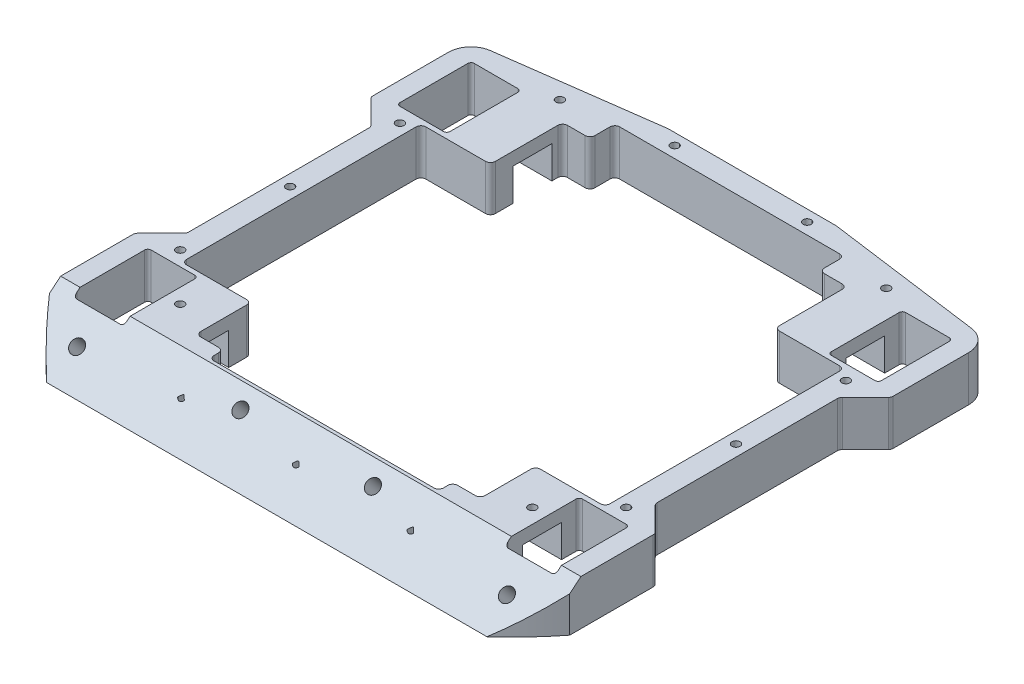
from build123d import *

# Parameters (mm, degrees)
SKETCH1_W                 = 161
SKETCH1_H                 = 154.75
OUTLINE_DEPTH             = 14
SKETCH2_W                 = 15.5
SKETCH2_H                 = 23
THRU_ALL_DEPTH            = 15
SKETCH14_W                = 87.977155452
SKETCH14_H                = 113.473818773
LAZY_EXTRA_DEPTH          = 15
SKETCH3_W                 = 23.5
SKETCH3_H                 = 12
MOTOR_HUTS_DEPTH          = 10
WHEEL_WELL_R              = 1
OUTER_CUTOUTS_DEPTH       = 15
SKETCH13_R                = 119.159432218
SKETCH13_R_2              = 102.197163823
CUT_EXTRUDE1_DEPTH        = 15
FILLET_THE_REST_R         = 1.5
WEDGE_CUT_DEPTH           = 162
TOP_SCREWS_D              = 2.5
TOP_SCREWS_DEPTH          = 6.5
TOP_SCREWS_TIP            = 0.751075774
BOTTOM_SCREWS_D           = 2.5
BOTTOM_SCREWS_DEPTH       = 7.5
BOTTOM_SCREWS_TIP         = 0.751075774
M5X0_8_TAPPED_HOLE1_D     = 4.2
M5X0_8_TAPPED_HOLE1_DEPTH = 7.4
M5X0_8_TAPPED_HOLE1_TIP   = 1.2618073


with BuildPart() as part:
    # Sketch1 → outline (new body)
    with BuildSketch(Plane(origin=(0, 0, 0), x_dir=(1, 0, 0), z_dir=(0, 1, 0))):
        with Locations((0, -3.375)):
            Rectangle(SKETCH1_W, SKETCH1_H)
    extrude(amount=OUTLINE_DEPTH)

    # Sketch2 → thru-all (cut, through all)
    with BuildSketch(Plane(origin=(0, 14, 0), x_dir=(1, 0, 0), z_dir=(0, 1, 0))):
        Polygon((-35.5, 67), (35.5, 67), (35.5, 37), (65.5, 37), (65.5, -37), (35.5, -37), (35.5, -58.5), (-35.5, -58.5), (-35.5, -37), (-65.5, -37), (-65.5, 37), (-35.5, 37), align=None)
        with Locations((-66.75, 50)):
            Rectangle(SKETCH2_W, SKETCH2_H)
        with Locations((66.75, 50)):
            Rectangle(SKETCH2_W, SKETCH2_H)
        with Locations((66.75, -50)):
            Rectangle(SKETCH2_W, SKETCH2_H)
        with Locations((-66.75, -50)):
            Rectangle(SKETCH2_W, SKETCH2_H)
    extrude(amount=-THRU_ALL_DEPTH, mode=Mode.SUBTRACT)

    # Sketch14 → lazy extra (cut, through all)
    with BuildSketch(Plane(origin=(0, 14, 0), x_dir=(1, 0, 0), z_dir=(0, 1, 0))):
        with Locations((0, 2.593800519)):
            Rectangle(SKETCH14_W, SKETCH14_H)
    extrude(amount=-LAZY_EXTRA_DEPTH, mode=Mode.SUBTRACT)

    # Sketch3 → motor huts (cut)
    with BuildSketch(Plane.XZ):
        with Locations((-47.25, 50)):
            Rectangle(SKETCH3_W, SKETCH3_H)
        with Locations((47.25, 50)):
            Rectangle(SKETCH3_W, SKETCH3_H)
        with Locations((47.25, -50)):
            Rectangle(SKETCH3_W, SKETCH3_H)
        with Locations((-47.25, -50)):
            Rectangle(SKETCH3_W, SKETCH3_H)
    extrude(amount=-MOTOR_HUTS_DEPTH, mode=Mode.SUBTRACT)

    # wheel well
    wheel_well_edges = [part.edges().sort_by_distance(p)[0] for p in [
        (-59, 7, -38.5),
        (-74.5, 7, -38.5),
        (-74.5, 7, -61.5),
        (-59, 7, -61.5),
        (59, 7, 38.5),
        (74.5, 7, 38.5),
        (74.5, 7, 61.5),
        (59, 7, 61.5),
        (74.5, 7, -61.5),
        (74.5, 7, -38.5),
        (59, 7, -38.5),
        (59, 7, -61.5),
        (-74.5, 7, 61.5),
        (-74.5, 7, 38.5),
        (-59, 7, 38.5),
        (-59, 7, 61.5),
    ]]
    fillet(wheel_well_edges, radius=WHEEL_WELL_R)

    # Sketch5 → outer cutouts (cut, through all)
    with BuildSketch(Plane(origin=(0, 14, 0), x_dir=(1, 0, 0), z_dir=(0, 1, 0))):
        Polygon((-80.5, 36.5), (-72.5, 28.5), (-72.5, -28.5), (-80.5, -36.5), align=None)
        with BuildLine():
            Line((-74.43988001, 67.436614849), (-26, 74))
            Line((-26, 74), (-26, 78.237510553))
            Line((-26, 78.237510553), (-88.236887357, 78.237510553))
            Line((-88.236887357, 78.237510553), (-88.236887357, 60.5))
            Line((-88.236887357, 60.5), (-80.5, 60.5))
            ThreePointArc((-80.5, 60.5), (-78.771582308, 65.10547717), (-74.43988001, 67.436614849))
        make_face()
        with BuildLine():
            Line((26, 78.237510553), (26, 74))
            Line((26, 74), (74.43988001, 67.436614849))
            ThreePointArc((74.43988001, 67.436614849), (78.771582308, 65.10547717), (80.5, 60.5))
            Line((80.5, 60.5), (88.236887357, 60.5))
            Line((88.236887357, 60.5), (88.236887357, 78.237510553))
            Line((88.236887357, 78.237510553), (26, 78.237510553))
        make_face()
        Polygon((80.5, 36.5), (80.5, -36.5), (72.5, -28.5), (72.5, 28.5), align=None)
    extrude(amount=-OUTER_CUTOUTS_DEPTH, mode=Mode.SUBTRACT)

    # Sketch13 → Cut-Extrude1 (cut, through all)
    with BuildSketch(Plane(origin=(0, 14, 0), x_dir=(1, 0, 0), z_dir=(0, 1, 0))):
        Circle(SKETCH13_R)
        Circle(SKETCH13_R_2, mode=Mode.SUBTRACT)
    extrude(amount=-CUT_EXTRUDE1_DEPTH, mode=Mode.SUBTRACT)

    # fillet the rest
    fillet_the_rest_edges = [part.edges().sort_by_distance(p)[0] for p in [
        (35.5, 7, -59.330709905),
        (-43.988577726, 7, -37),
        (43.988577726, 7, 37),
        (43.988577726, 7, -37),
        (43.988577726, 7, -59.330709905),
        (35.5, 12, 54.143108868),
        (-43.988577726, 7, 37),
        (-35.5, 7, -59.330709905),
        (-43.988577726, 7, -59.330709905),
        (-43.988577726, 12, 54.143108868),
        (-35.5, 12, 54.143108868),
        (43.988577726, 12, 54.143108868),
        (-80.5, 7, 36.5),
        (-80.5, 7, -36.5),
        (-72.5, 7, -28.5),
        (-72.5, 7, 28.5),
        (65.5, 7, -37),
        (65.5, 7, 37),
        (35.5, 7, 58.5),
        (-35.5, 7, 58.5),
        (72.5, 7, -28.5),
        (80.5, 7, -36.5),
        (80.5, 7, 36.5),
        (72.5, 7, 28.5),
        (-65.5, 7, 37),
        (-65.5, 7, -37),
        (-35.5, 7, -67),
        (35.5, 7, -67),
    ]]
    fillet(fillet_the_rest_edges, radius=FILLET_THE_REST_R)

    # Sketch4 → wedge cut (cut, through all)
    with BuildSketch(Plane(origin=(80.5, 0, 0), x_dir=(0, 0, -1), z_dir=(1, 0, 0))):
        Polygon((-59.5, 14), (-76.184550296, 0), (-154.643584696, 0), (-154.643584696, 14), (-76.184550296, 14), align=None)
    extrude(amount=-WEDGE_CUT_DEPTH, mode=Mode.SUBTRACT)

    # top screws
    with Locations(Plane(origin=(0, 14, 0), x_dir=(1, 0, 0), z_dir=(0, 1, 0))):
        with Locations((-69, -34), (-69, 0), (-54.5, -48.5), (54.5, -48.5), (69, 0), (69, -34), (69, 34), (-69, 34), (-50.5, 65), (-20.5, 70.5), (20.5, 70.5), (50.5, 65)):
            Hole(TOP_SCREWS_D / 2, depth=TOP_SCREWS_DEPTH)
            with Locations((0, 0, -(TOP_SCREWS_DEPTH + TOP_SCREWS_TIP / 2))):  # 118° drill point
                Cone(0, TOP_SCREWS_D / 2, TOP_SCREWS_TIP, mode=Mode.SUBTRACT)

    # bottom screws
    with Locations(Plane(origin=(0, 0, 0), x_dir=(-1, 0, 0), z_dir=(0, -1, 0))):
        with Locations((35.5, -66.5), (69, -24), (55.5, -40.5), (55.5, -59.5), (0, -66.5), (-55.5, -59.5), (-55.5, -40.5), (-69, -24), (-35.5, -66.5), (-69, 24), (-55.5, 40.5), (-55.5, 59.5), (40.5, 67), (55.5, 59.5), (55.5, 40.5), (69, 24), (0, 70.5), (-40.5, 67)):
            Hole(BOTTOM_SCREWS_D / 2, depth=BOTTOM_SCREWS_DEPTH)
            with Locations((0, 0, -(BOTTOM_SCREWS_DEPTH + BOTTOM_SCREWS_TIP / 2))):  # 118° drill point
                Cone(0, BOTTOM_SCREWS_D / 2, BOTTOM_SCREWS_TIP, mode=Mode.SUBTRACT)

    # M5x0.8 Tapped Hole1
    with Locations(Plane(origin=(0, 37.513567896, 31.477620985), x_dir=(1, 0, 0), z_dir=(0, 0.766044443, 0.64278761))):
        with Locations((-66.5, -48.191432409), (-20.5, -42.275210541), (20.5, -42.275210541), (66.5, -48.191432409)):
            Hole(M5X0_8_TAPPED_HOLE1_D / 2, depth=M5X0_8_TAPPED_HOLE1_DEPTH)
            with Locations((0, 0, -(M5X0_8_TAPPED_HOLE1_DEPTH + M5X0_8_TAPPED_HOLE1_TIP / 2))):  # 118° drill point
                Cone(0, M5X0_8_TAPPED_HOLE1_D / 2, M5X0_8_TAPPED_HOLE1_TIP, mode=Mode.SUBTRACT)


solid = part.part
